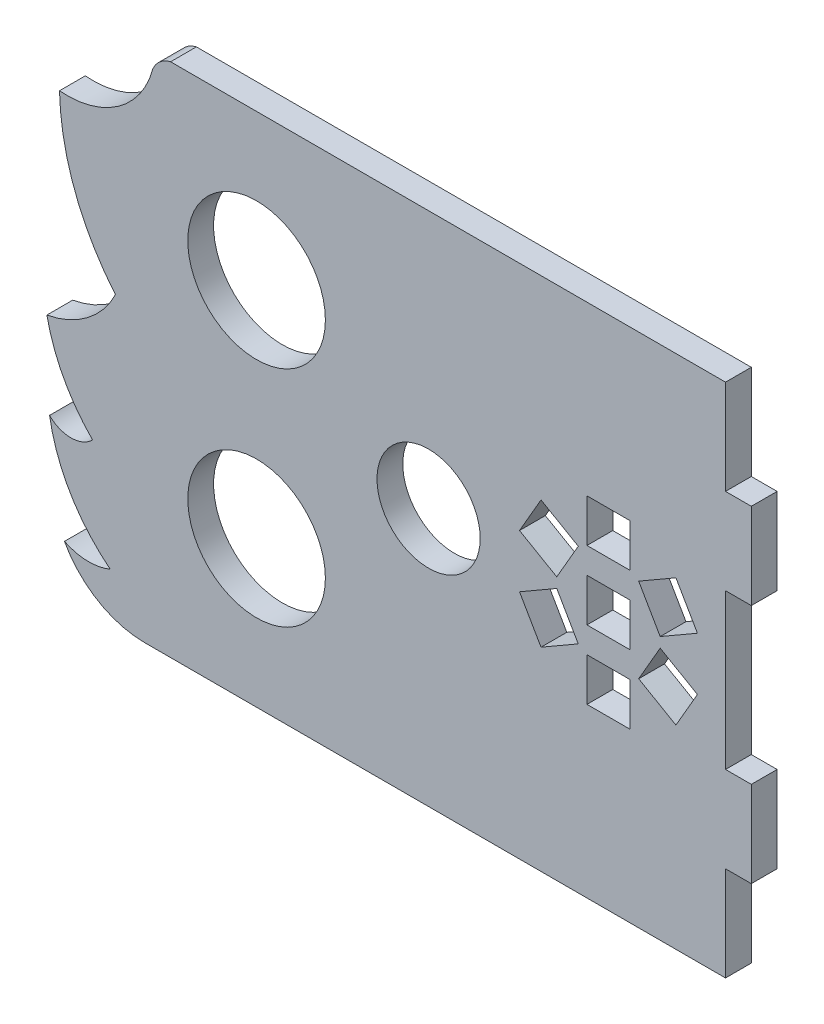
from build123d import *

# Parameters (mm, degrees)
MODEL_R                 = 8
MODEL_R_2               = 6
MODEL_W                 = 5
MODEL_H                 = 5
SALIENTE_EXTRUIR1_DEPTH = 3


with BuildPart() as part:
    # Model → Saliente-Extruir1 (new body)
    with BuildSketch(Plane.XY):
        with BuildLine():
            Line((81.032103119, 50.181312), (81.032103119, 60.181312))
            Line((81.032103119, 60.181312), (78.032103119, 60.181312))
            Line((78.032103119, 60.181312), (78.032103119, 71.181312))
            Line((78.032103119, 71.181312), (66.95908996, 71.181312))
            Line((66.95908996, 71.181312), (56.219592514, 71.181312))
            Line((56.219592514, 71.181312), (47.225756879, 71.181312))
            Line((47.225756879, 71.181312), (42.176203424, 71.181312))
            Line((42.176203424, 71.181312), (32.39338928, 71.181312))
            Line((32.39338928, 71.181312), (26.994131201, 71.181312))
            Line((26.994131201, 71.181312), (16.997485054, 71.181312))
            Line((16.997485054, 71.181312), (13.507028058, 71.181312))
            ThreePointArc((13.507028058, 71.181312), (12.2632217, 70.549216368), (11.439835667, 69.42287957))
            ThreePointArc((11.439835667, 69.42287957), (7.401938773, 63.637457593), (0.58912476, 61.804077109))
            ThreePointArc((0.58912476, 61.804077109), (2.373680587, 52.610452717), (7.096904361, 44.523517195))
            ThreePointArc((7.096904361, 44.523517195), (3.82332943, 40.564109484), (-0.875345958, 38.486694782))
            ThreePointArc((-0.875345958, 38.486694782), (1.059461304, 33.138647965), (4.434592413, 28.561140576))
            ThreePointArc((4.434592413, 28.561140576), (1.939393599, 27.514090743), (-0.565354439, 28.538086707))
            ThreePointArc((-0.565354439, 28.538086707), (1.851215322, 21.899286601), (6.48990044, 16.57048968))
            ThreePointArc((6.48990044, 16.57048968), (3.812833965, 16.075789072), (1.167157726, 16.717513967))
            ThreePointArc((1.167157726, 16.717513967), (5.078186337, 12.669096828), (10.507028058, 11.181312))
            Line((10.507028058, 11.181312), (21.6574548, 11.181312))
            Line((21.6574548, 11.181312), (43.769565589, 11.181312))
            Line((43.769565589, 11.181312), (66.512005339, 11.181312))
            Line((66.512005339, 11.181312), (78.032103119, 11.181312))
            Line((78.032103119, 11.181312), (78.032103119, 22.181312))
            Line((78.032103119, 22.181312), (81.032103119, 22.181312))
            Line((81.032103119, 22.181312), (81.032103119, 32.181312))
            Line((81.032103119, 32.181312), (78.032103119, 32.181312))
            Line((78.032103119, 32.181312), (78.032103119, 50.181312))
            Line((78.032103119, 50.181312), (81.032103119, 50.181312))
        make_face()
        with Locations((23.507028058, 54.181312)):
            Circle(MODEL_R, mode=Mode.SUBTRACT)
        with Locations((43.507028058, 41.181312)):
            Circle(MODEL_R_2, mode=Mode.SUBTRACT)
        with Locations((23.507028058, 28.181312)):
            Circle(MODEL_R, mode=Mode.SUBTRACT)
        with Locations((64.423022125, 41.181312)):
            Rectangle(MODEL_W, MODEL_H, mode=Mode.SUBTRACT)
        with Locations((64.423022125, 33.181312)):
            Rectangle(MODEL_W, MODEL_H, mode=Mode.SUBTRACT)
        Polygon((72.266288865, 48.59637551), (67.936161846, 46.09637551), (70.436161846, 41.766248491), (74.766288865, 44.266248491), align=None, mode=Mode.SUBTRACT)
        Polygon((67.936161846, 36.266248491), (72.266288865, 33.766248491), (74.766288865, 38.09637551), (70.436161846, 40.59637551), align=None, mode=Mode.SUBTRACT)
        with Locations((64.423022125, 49.181312)):
            Rectangle(MODEL_W, MODEL_H, mode=Mode.SUBTRACT)
        Polygon((56.579755385, 33.766248491), (60.909882404, 36.266248491), (58.409882404, 40.59637551), (54.079755385, 38.09637551), align=None, mode=Mode.SUBTRACT)
        Polygon((60.909882404, 46.09637551), (56.579755385, 48.59637551), (54.079755385, 44.266248491), (58.409882404, 41.766248491), align=None, mode=Mode.SUBTRACT)
    extrude(amount=SALIENTE_EXTRUIR1_DEPTH)


solid = part.part
